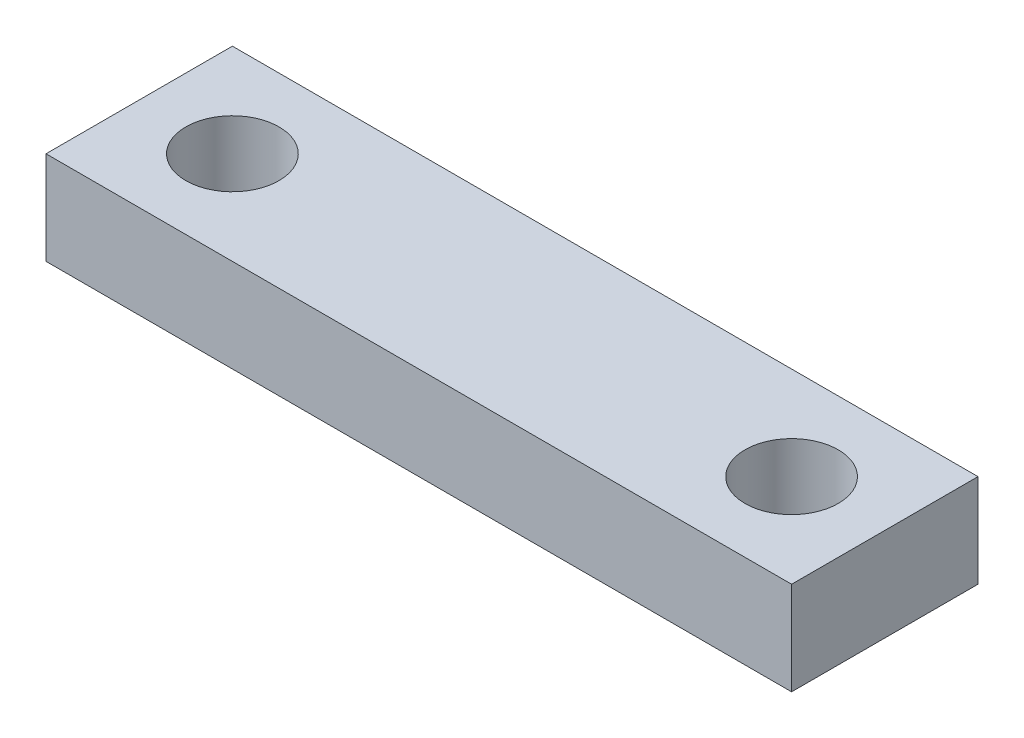
from build123d import *

# Parameters (mm, degrees)
SKETCH1_W           = 80
SKETCH1_H           = 20
SKETCH1_R           = 5
BOSS_EXTRUDE1_DEPTH = 10


with BuildPart() as part:
    # Sketch1 → Boss-Extrude1 (new body)
    with BuildSketch(Plane(origin=(0, 0, 0), x_dir=(1, 0, 0), z_dir=(0, 1, 0))):
        with Locations((40, 10)):
            Rectangle(SKETCH1_W, SKETCH1_H)
        with Locations((10, 10)):
            Circle(SKETCH1_R, mode=Mode.SUBTRACT)
        with Locations((70, 10)):
            Circle(SKETCH1_R, mode=Mode.SUBTRACT)
    extrude(amount=BOSS_EXTRUDE1_DEPTH)


solid = part.part
